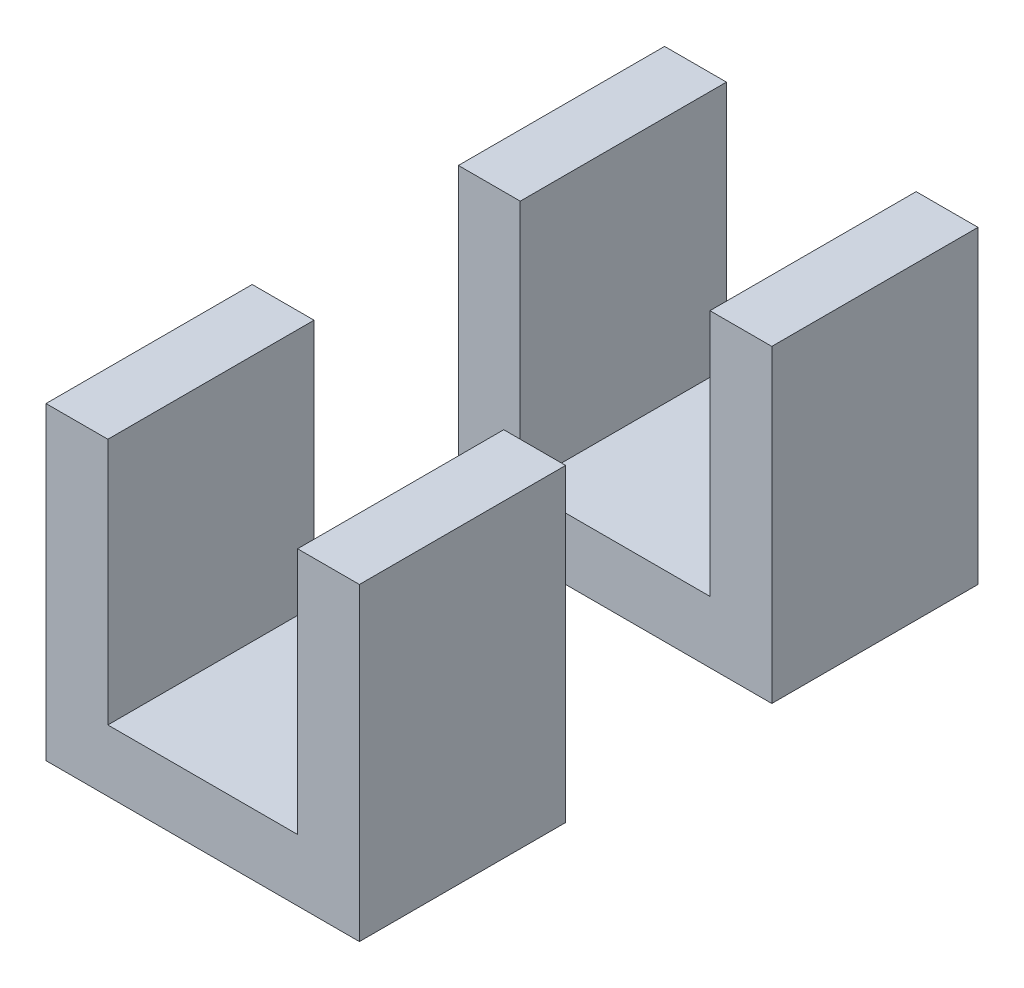
from build123d import *

# Parameters (mm, degrees)
BOSS_EXTRUDE1_DEPTH = 10
LPATTERN3_COUNT     = 2
LPATTERN3_PITCH     = 20


with BuildPart() as part:
    # Sketch1 → Boss-Extrude1 (new body)
    with BuildSketch(Plane.XY):
        Polygon((-4.6, 15), (-4.6, 3), (4.6, 3), (4.6, 15), (7.6, 15), (7.6, 0), (-7.6, 0), (-7.6, 15), align=None)
    extrude(amount=BOSS_EXTRUDE1_DEPTH)


with BuildPart() as lpattern3_1:
    # LPattern3: pattern copy
    add(part.part.moved(Location(Vector(0, 0, 1) * (1 * LPATTERN3_PITCH))))


solid = Compound([part.part, lpattern3_1.part])
